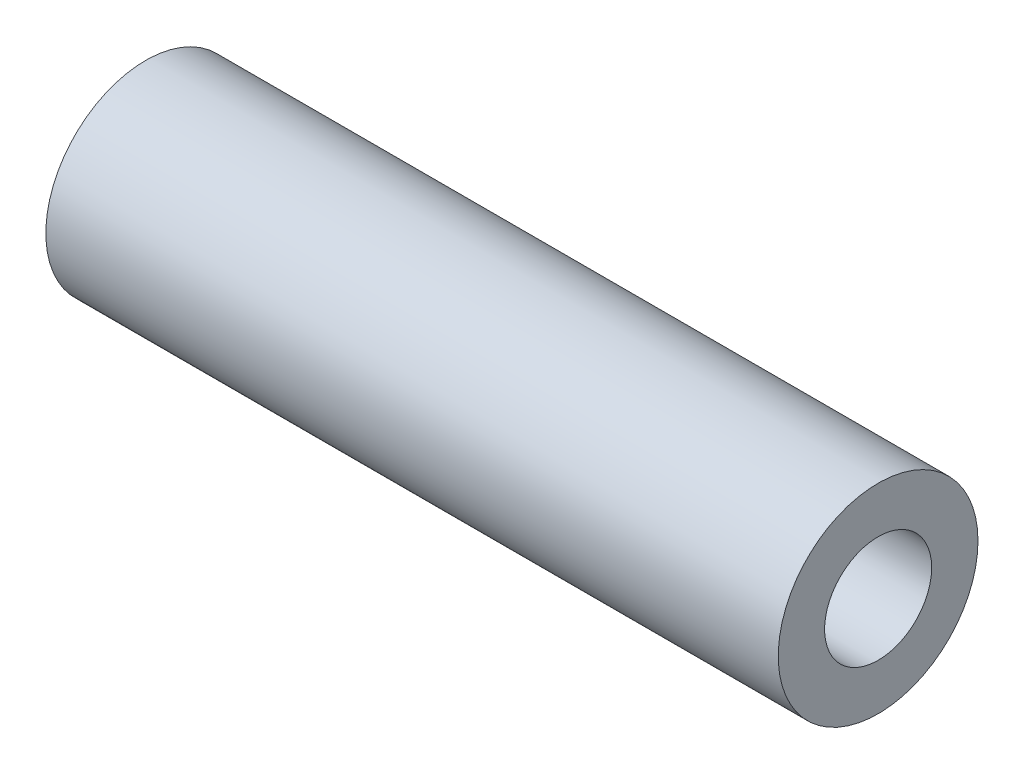
from build123d import *

# Parameters (mm, degrees)
SKETCH1_R           = 4.7625
SKETCH1_R_2         = 2.5527
BOSS_EXTRUDE1_DEPTH = 34.925


with BuildPart() as part:
    # Sketch1 → Boss-Extrude1 (new body)
    with BuildSketch(Plane(origin=(0, 0, 0), x_dir=(0, 0, -1), z_dir=(1, 0, 0))):
        Circle(SKETCH1_R)
        Circle(SKETCH1_R_2, mode=Mode.SUBTRACT)
    extrude(amount=BOSS_EXTRUDE1_DEPTH)


solid = part.part
